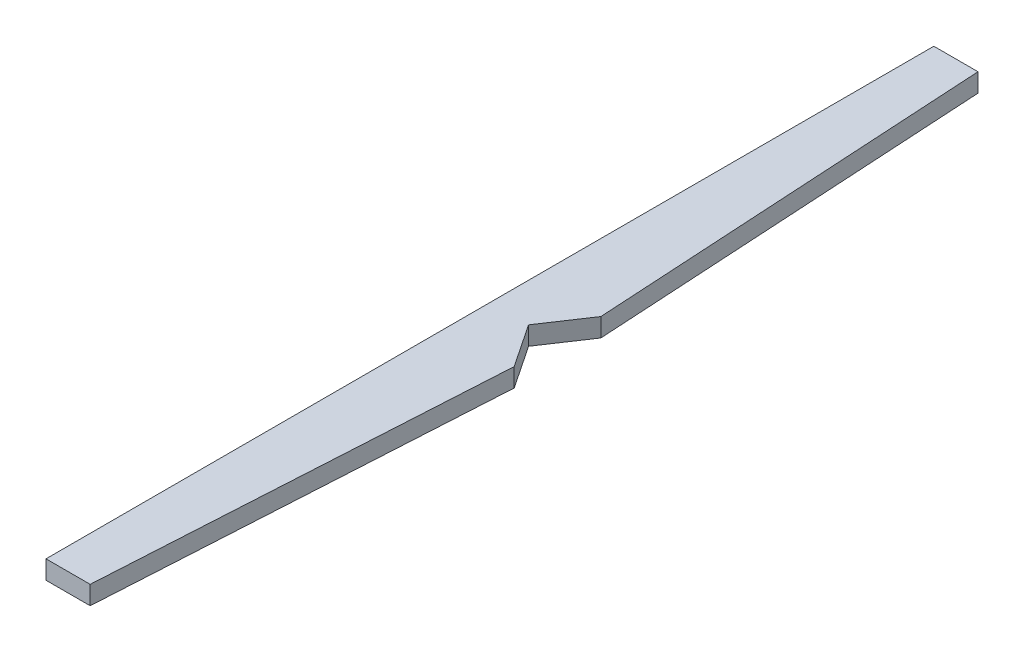
from build123d import *

# Parameters (mm, degrees)
BOSS_EXTRUDE1_DEPTH = 15


with BuildPart() as part:
    # Sketch1 → Boss-Extrude1 (new body)
    with BuildSketch(Plane(origin=(0, 0, 0), x_dir=(1, 0, 0), z_dir=(0, 1, 0))):
        Polygon((0, 358.35), (0, -358.35), (35.650600343, -358.35), (54.572500068, -34.997934227), (31.19655837, 0), (54.572500068, 34.997934227), (35.650600343, 358.35), align=None)
    extrude(amount=BOSS_EXTRUDE1_DEPTH)


solid = part.part
